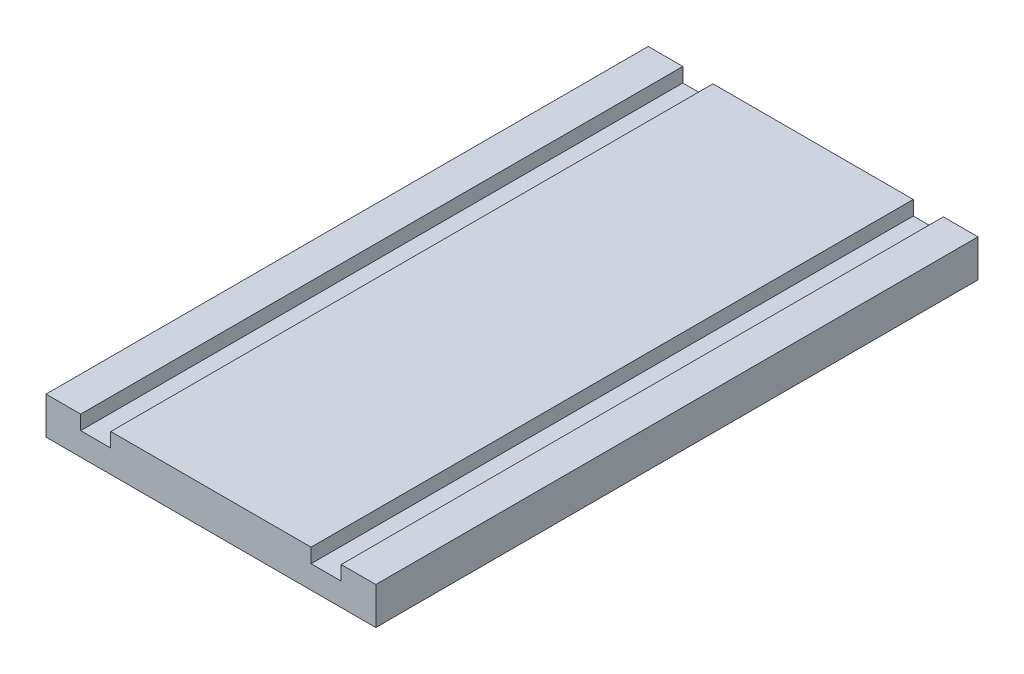
from build123d import *

# Parameters (mm, degrees)
SKETCH1_W           = 230
SKETCH1_H           = 420
BOSS_EXTRUDE1_DEPTH = 26
SKETCH2_W           = 21
SKETCH2_H           = 420
CUT_EXTRUDE1_DEPTH  = 10


with BuildPart() as part:
    # Sketch1 → Boss-Extrude1 (new body)
    with BuildSketch(Plane(origin=(0, 0, 0), x_dir=(1, 0, 0), z_dir=(0, 1, 0))):
        Rectangle(SKETCH1_W, SKETCH1_H)
    extrude(amount=BOSS_EXTRUDE1_DEPTH)

    # Sketch2 → Cut-Extrude1 (cut)
    with BuildSketch(Plane(origin=(0, 26, 0), x_dir=(1, 0, 0), z_dir=(0, 1, 0))):
        with Locations((-80.35, 0)):
            Rectangle(SKETCH2_W, SKETCH2_H)
        with Locations((80.35, 0)):
            Rectangle(SKETCH2_W, SKETCH2_H)
    extrude(amount=-CUT_EXTRUDE1_DEPTH, mode=Mode.SUBTRACT)


solid = part.part
